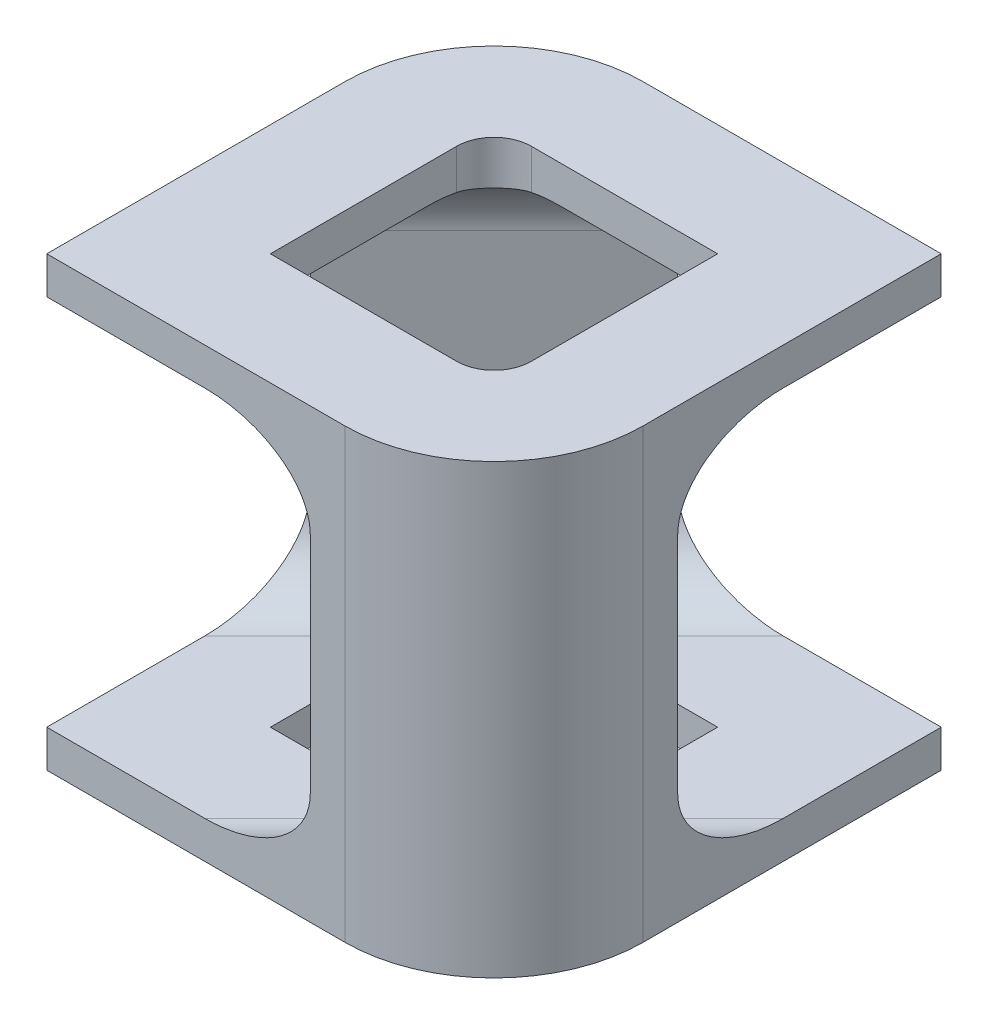
from build123d import *

# Parameters (mm, degrees)
BOSS_EXTRUDE1_DEPTH     = 76.2
CUT_EXTRUDE4_DEPTH      = 50.546
CUT_EXTRUDE4_DEPTH_BACK = 82.042


with BuildPart() as part:
    # Sketch1 → Boss-Extrude1 (new body)
    with BuildSketch(Plane(origin=(0, 0, 0), x_dir=(1, 0, 0), z_dir=(0, 1, 0))):
        with BuildLine():
            Line((0, 0), (50.8, 0))
            ThreePointArc((50.8, 0), (68.760512242, 7.439487758), (76.2, 25.4))
            Line((76.2, 25.4), (76.2, 76.2))
            Line((76.2, 76.2), (25.4, 76.2))
            ThreePointArc((25.4, 76.2), (7.439487758, 68.760512242), (0, 50.8))
            Line((0, 50.8), (0, 0))
        make_face()
        with BuildLine():
            Line((19.05, 19.05), (50.8, 19.05))
            ThreePointArc((50.8, 19.05), (55.290128061, 20.909871939), (57.15, 25.4))
            Line((57.15, 25.4), (57.15, 57.15))
            Line((57.15, 57.15), (25.4, 57.15))
            ThreePointArc((25.4, 57.15), (20.909871939, 55.290128061), (19.05, 50.8))
            Line((19.05, 50.8), (19.05, 19.05))
        make_face(mode=Mode.SUBTRACT)
    extrude(amount=BOSS_EXTRUDE1_DEPTH)

    # Sketch3 → Cut-Extrude4 (cut, two sides)
    with BuildSketch(Plane(origin=(25.4, 0, -25.4), x_dir=(0.707106781, 0, 0.707106781), z_dir=(-0.707106781, 0, 0.707106781))) as cut_extrude4_sk:
        with BuildLine():
            Line((-31.75, 38.1), (-31.75, 19.05))
            ThreePointArc((-31.75, 19.05), (-28.030256121, 10.069743879), (-19.05, 6.35))
            Line((-19.05, 6.35), (19.05, 6.35))
            ThreePointArc((19.05, 6.35), (28.030256121, 10.069743879), (31.75, 19.05))
            Line((31.75, 19.05), (31.75, 38.1))
            Line((31.75, 38.1), (31.75, 57.15))
            ThreePointArc((31.75, 57.15), (28.030256121, 66.130256121), (19.05, 69.85))
            Line((19.05, 69.85), (-19.05, 69.85))
            ThreePointArc((-19.05, 69.85), (-28.030256121, 66.130256121), (-31.75, 57.15))
            Line((-31.75, 57.15), (-31.75, 38.1))
        make_face()
    extrude(amount=CUT_EXTRUDE4_DEPTH, mode=Mode.SUBTRACT)
    extrude(cut_extrude4_sk.sketch, amount=-CUT_EXTRUDE4_DEPTH_BACK, mode=Mode.SUBTRACT)


solid = part.part
